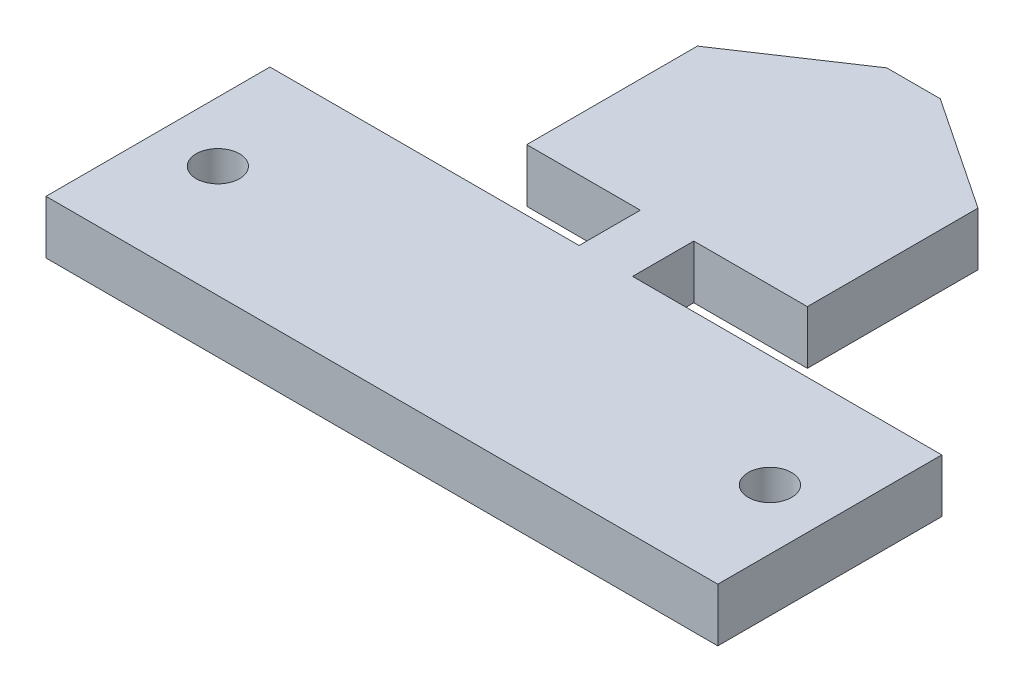
from build123d import *

# Parameters (mm, degrees)
BOSS_EXTRUDE1_DEPTH = 3.5814
SKETCH2_R           = 1.45
CUT_EXTRUDE1_DEPTH  = 4.5814
BOSS_EXTRUDE2_DEPTH = 3.5814


with BuildPart() as part:
    # Sketch1 → Boss-Extrude1 (new body)
    with BuildSketch(Plane(origin=(0, 0, 0), x_dir=(1, 0, 0), z_dir=(0, 1, 0))):
        Polygon((-22.5, -17.05), (22.5, -17.05), (22.5, -2.05), (1.7907, -2.05), (1.7907, 2.05), (9.398, 2.05), (1.7907, 7.13), (-1.7907, 7.13), (-9.398, 2.05), (-1.7907, 2.05), (-1.7907, -2.05), (-22.5, -2.05), align=None)
    extrude(amount=BOSS_EXTRUDE1_DEPTH)

    # Sketch2 → Cut-Extrude1 (cut, through all)
    with BuildSketch(Plane(origin=(0, 3.5814, 0), x_dir=(1, 0, 0), z_dir=(0, 1, 0))):
        with Locations((-18.49, -9.55)):
            Circle(SKETCH2_R)
        with Locations((18.49, -9.55)):
            Circle(SKETCH2_R)
    extrude(amount=-CUT_EXTRUDE1_DEPTH, mode=Mode.SUBTRACT)

    # Sketch3 → Boss-Extrude2 (add)
    with BuildSketch(Plane(origin=(0, 3.5814, 0), x_dir=(1, 0, 0), z_dir=(0, 1, 0))):
        Polygon((1.7907, 18.56), (9.398, 13.48), (9.398, 2.05), (1.7907, 7.13), (-1.7907, 7.13), (-9.398, 2.05), (-9.398, 13.48), (-1.7907, 18.56), align=None)
    extrude(amount=-BOSS_EXTRUDE2_DEPTH)


solid = part.part
